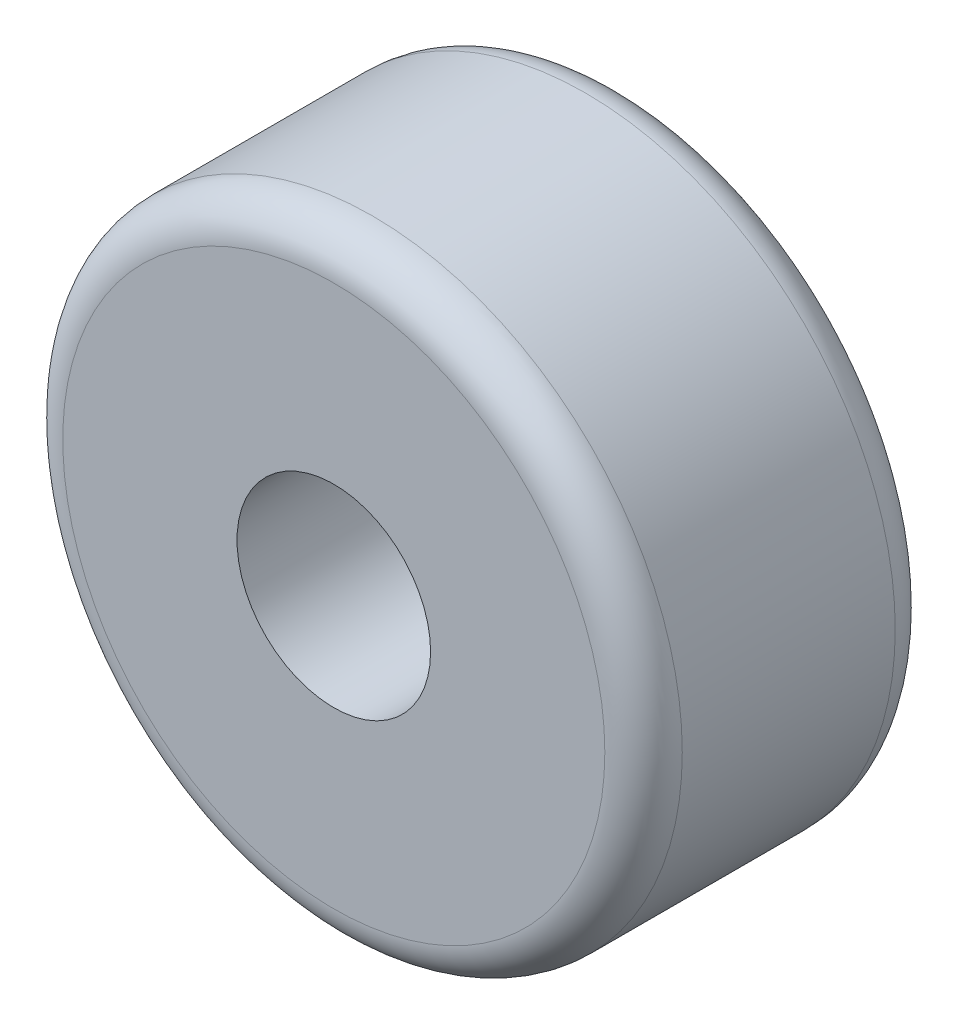
from build123d import *

# Parameters (mm, degrees)
ESQUISSE1_R        = 80
ESQUISSE1_R_2      = 25
BOSS_EXTRU_1_DEPTH = 75
CONG_1_R           = 10


with BuildPart() as part:
    # Esquisse1 → Boss.-Extru.1 (new body)
    with BuildSketch(Plane.XY):
        Circle(ESQUISSE1_R)
        Circle(ESQUISSE1_R_2, mode=Mode.SUBTRACT)
    extrude(amount=BOSS_EXTRU_1_DEPTH)

    # Congé1
    cong_1_edges = [part.edges().sort_by_distance(p)[0] for p in [
        (-80, 0, 75),
        (-80, 0, 0),
    ]]
    fillet(cong_1_edges, radius=CONG_1_R)


solid = part.part
